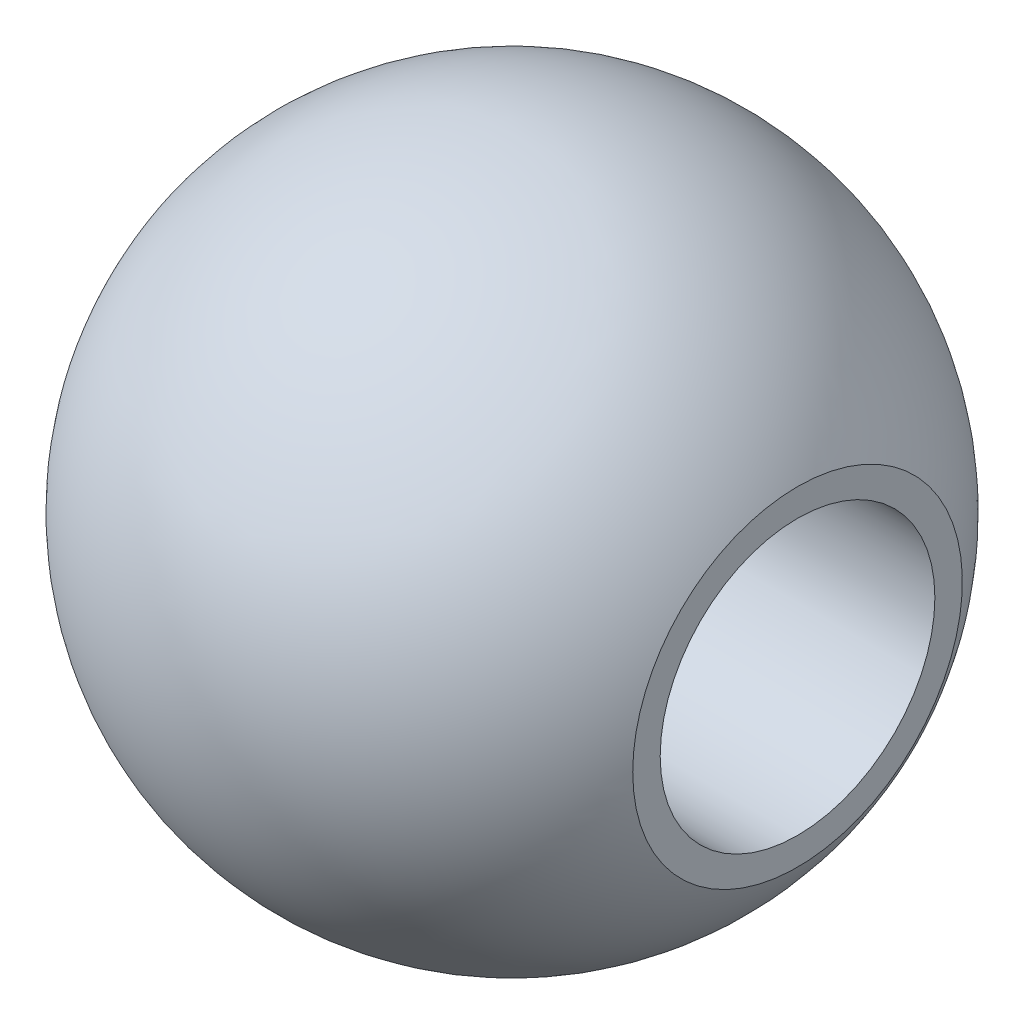
from build123d import *

# Parameters (mm, degrees)
TAP_DRILL_FOR_M3X0_5_TAP1_D     = 2.5
TAP_DRILL_FOR_M3X0_5_TAP1_DEPTH = 4
TAP_DRILL_FOR_M3X0_5_TAP1_TIP   = 0.751075774


with BuildPart() as part:
    # Sketch1 → Revolve1 (revolve)
    with BuildSketch(Plane.XY):
        with BuildLine():
            Line((-3, 0), (2.598076211, 0))
            Line((2.598076211, 0), (2.598076211, 1.5))
            ThreePointArc((2.598076211, 1.5), (-0.776457135, 2.897777479), (-3, 0))
        make_face()
    revolve(axis=Axis((-3.5, 0, 0), (1, 0, 0)))

    # Tap Drill for M3x0.5 Tap1
    with Locations(Plane(origin=(3, 0, 0), x_dir=(0, 0, -1), z_dir=(1, 0, 0))):
        with Locations((0, 0)):
            Hole(TAP_DRILL_FOR_M3X0_5_TAP1_D / 2, depth=TAP_DRILL_FOR_M3X0_5_TAP1_DEPTH)
            with Locations((0, 0, -(TAP_DRILL_FOR_M3X0_5_TAP1_DEPTH + TAP_DRILL_FOR_M3X0_5_TAP1_TIP / 2))):  # 118° drill point
                Cone(0, TAP_DRILL_FOR_M3X0_5_TAP1_D / 2, TAP_DRILL_FOR_M3X0_5_TAP1_TIP, mode=Mode.SUBTRACT)


solid = part.part
